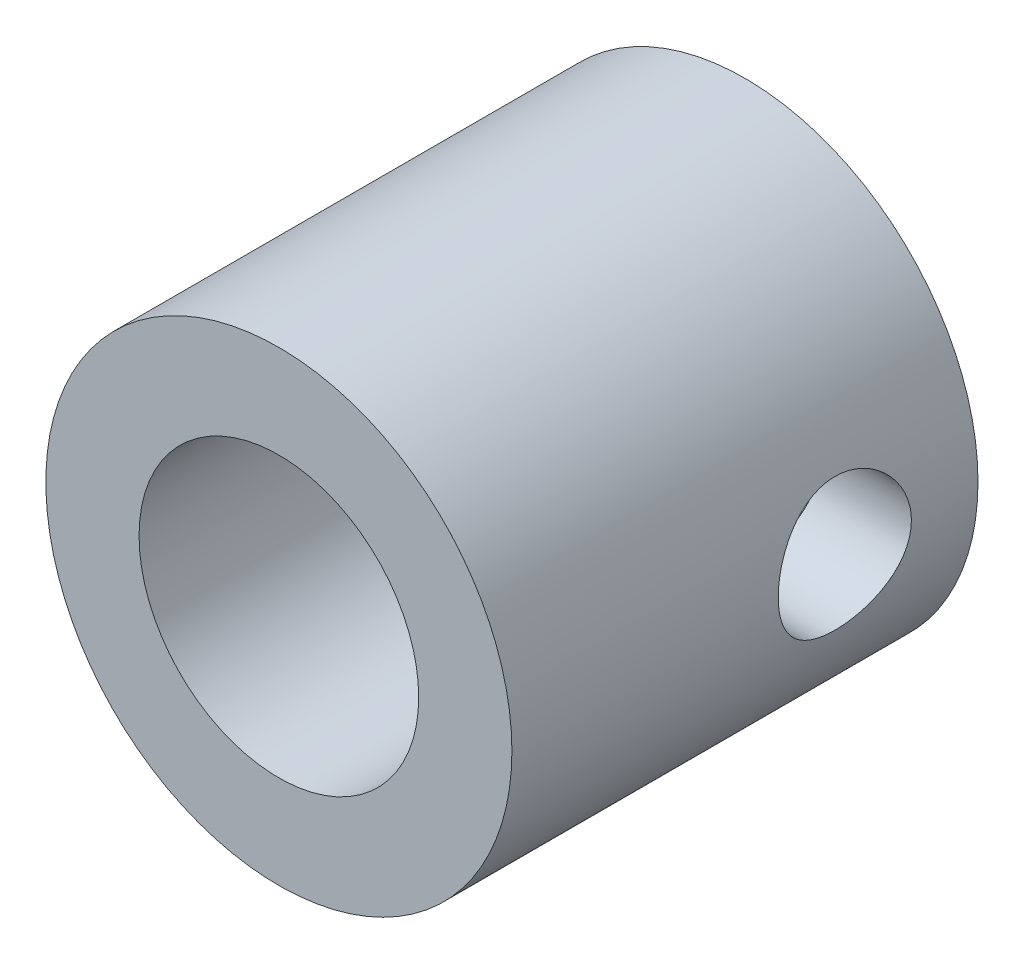
from build123d import *

# Parameters (mm, degrees)
SKETCH1_R               = 3.5
SKETCH1_R_2             = 2.1
BOSS_EXTRUDE1_DEPTH     = 7
SKETCH2_R               = 1
CUT_EXTRUDE1_DEPTH      = 1
CUT_EXTRUDE1_DEPTH_BACK = 8


with BuildPart() as part:
    # Sketch1 → Boss-Extrude1 (new body)
    with BuildSketch(Plane.XY):
        Circle(SKETCH1_R)
        Circle(SKETCH1_R_2, mode=Mode.SUBTRACT)
    extrude(amount=BOSS_EXTRUDE1_DEPTH)

    # Sketch2 → Cut-Extrude1 (cut, two sides)
    with BuildSketch(Plane(origin=(3.5, 0, 0), x_dir=(0, 0, -1), z_dir=(1, 0, 0))) as cut_extrude1_sk:
        with Locations((-2, 0)):
            Circle(SKETCH2_R)
    extrude(amount=CUT_EXTRUDE1_DEPTH, mode=Mode.SUBTRACT)
    extrude(cut_extrude1_sk.sketch, amount=-CUT_EXTRUDE1_DEPTH_BACK, mode=Mode.SUBTRACT)


solid = part.part
